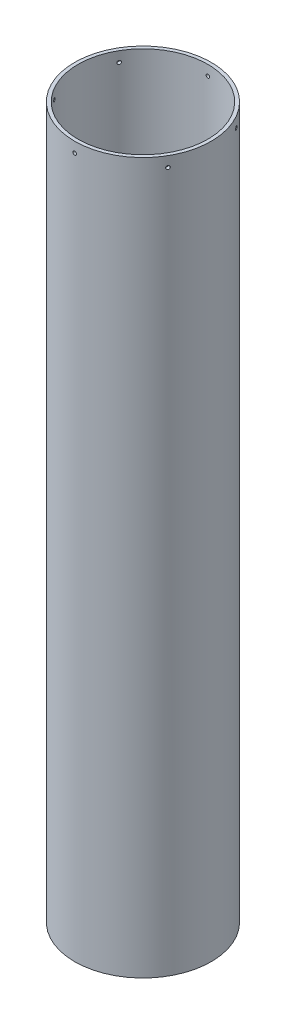
from build123d import *

# Parameters (mm, degrees)
SKETCH1_R           = 63.5
SKETCH1_R_2         = 60.325
BOSS_EXTRUDE1_DEPTH = 660.4
SKETCH4_W           = 1.63195
SKETCH4_H           = 63.5
CIRPATTERN1_COUNT   = 6


with BuildPart() as part:
    # Sketch1 → Boss-Extrude1 (new body)
    with BuildSketch(Plane(origin=(0, 0, 0), x_dir=(1, 0, 0), z_dir=(0, 1, 0))):
        Circle(SKETCH1_R)
        Circle(SKETCH1_R_2, mode=Mode.SUBTRACT)
    extrude(amount=BOSS_EXTRUDE1_DEPTH)

    # Sketch4 → #4 Clearance Hole2 (revolve, cut)
    with BuildSketch(Plane(origin=(0, 650.875, 0), x_dir=(0, 1, 0), z_dir=(1, 0, 0))):
        with Locations((0.815975, 31.75)):
            Rectangle(SKETCH4_W, SKETCH4_H)
    f_4_clearance_hole2 = revolve(axis=Axis((0, 650.875, -6.35), (0, 0, 1)), mode=Mode.SUBTRACT)

    # CirPattern1: #4 Clearance Hole2 ×6 about axis
    cirpattern1_axis = Axis((0, 660.4, 0), (0, 1, 0))
    for i in range(1, CIRPATTERN1_COUNT):
        add(f_4_clearance_hole2.rotate(cirpattern1_axis, i * 360 / CIRPATTERN1_COUNT), mode=Mode.SUBTRACT)


solid = part.part
